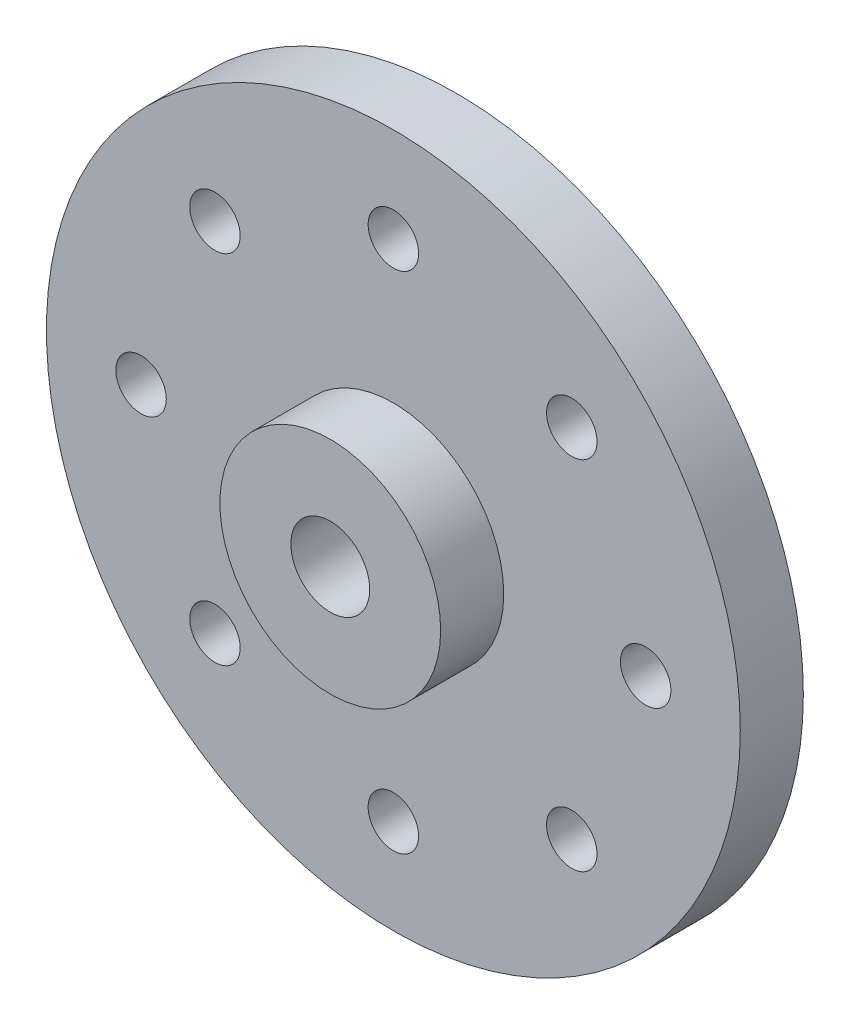
from build123d import *

# Parameters (mm, degrees)
SKETCH1_R                 = 11
BOSS_EXTRUDE1_DEPTH       = 2
SKETCH3_R                 = 3.5
BOSS_EXTRUDE2_DEPTH       = 2
M2X0_4_TAPPED_HOLE1_D     = 1.6
M2X0_4_TAPPED_HOLE1_DEPTH = 5.2
M2X0_4_TAPPED_HOLE1_TIP   = 0.480688495
SKETCH8_R                 = 2
SKETCH8_R_2               = 1.25
BOSS_EXTRUDE3_DEPTH       = 1
M3X0_5_TAPPED_HOLE1_D     = 2.5
M3X0_5_TAPPED_HOLE1_DEPTH = 7.5
M3X0_5_TAPPED_HOLE1_TIP   = 0.751075774


with BuildPart() as part:
    # Sketch1 → Boss-Extrude1 (new body)
    with BuildSketch(Plane.XY):
        Circle(SKETCH1_R)
    extrude(amount=BOSS_EXTRUDE1_DEPTH)

    # Sketch3 → Boss-Extrude2 (add)
    with BuildSketch(Plane.XY.offset(2)):
        Circle(SKETCH3_R)
    extrude(amount=BOSS_EXTRUDE2_DEPTH)

    # M2x0.4 Tapped Hole1
    with Locations(Plane.XY.offset(2)):
        with Locations((0, 8), (-5.656854249, 5.656854249), (-8, 0), (-5.656854249, -5.656854249), (0, -8), (5.656854249, -5.656854249), (8, 0), (5.656854249, 5.656854249)):
            Hole(M2X0_4_TAPPED_HOLE1_D / 2, depth=M2X0_4_TAPPED_HOLE1_DEPTH)
            with Locations((0, 0, -(M2X0_4_TAPPED_HOLE1_DEPTH + M2X0_4_TAPPED_HOLE1_TIP / 2))):  # 118° drill point
                Cone(0, M2X0_4_TAPPED_HOLE1_D / 2, M2X0_4_TAPPED_HOLE1_TIP, mode=Mode.SUBTRACT)

    # Sketch8 → Boss-Extrude3 (add)
    with BuildSketch(Plane(origin=(0, 0, 0), x_dir=(-1, 0, 0), z_dir=(0, 0, -1))):
        Circle(SKETCH8_R)
        Circle(SKETCH8_R_2, mode=Mode.SUBTRACT)
    extrude(amount=BOSS_EXTRUDE3_DEPTH)

    # M3x0.5 Tapped Hole1
    with Locations(Plane.XY.offset(4)):
        with Locations((0, 0)):
            Hole(M3X0_5_TAPPED_HOLE1_D / 2, depth=M3X0_5_TAPPED_HOLE1_DEPTH)
            with Locations((0, 0, -(M3X0_5_TAPPED_HOLE1_DEPTH + M3X0_5_TAPPED_HOLE1_TIP / 2))):  # 118° drill point
                Cone(0, M3X0_5_TAPPED_HOLE1_D / 2, M3X0_5_TAPPED_HOLE1_TIP, mode=Mode.SUBTRACT)


solid = part.part
